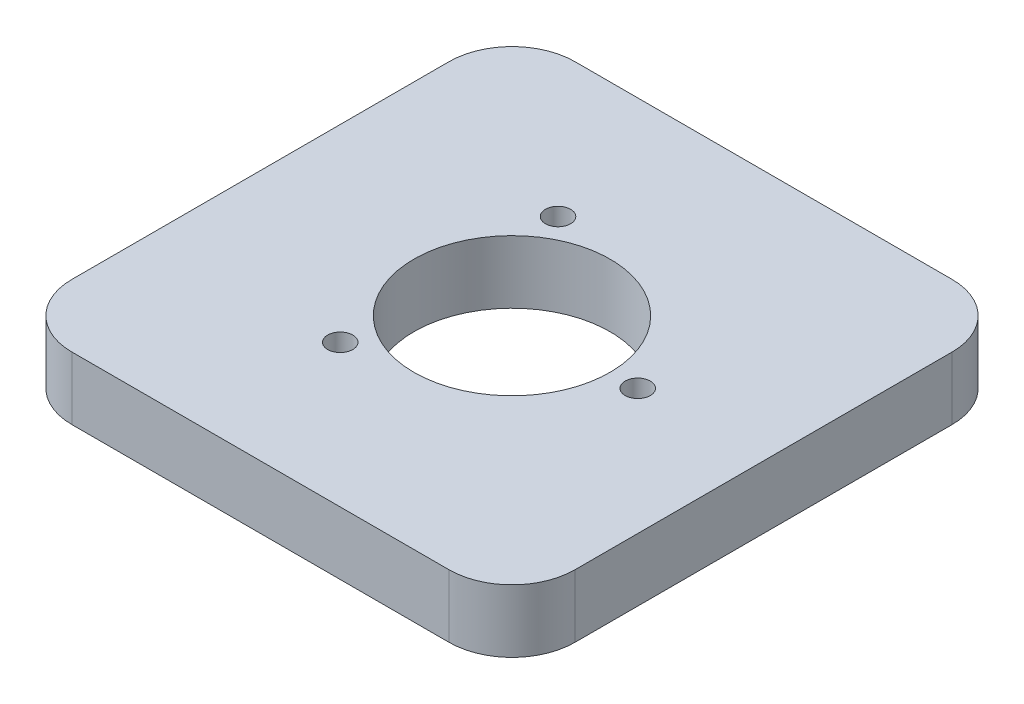
from build123d import *

# Parameters (mm, degrees)
SKETCH1_W           = 50.8
SKETCH1_H           = 50.8
BOSS_EXTRUDE1_DEPTH = 6.35
SKETCH2_R           = 9.906
CUT_EXTRUDE1_DEPTH  = 7.35
SKETCH3_R           = 1.27
CUT_EXTRUDE2_DEPTH  = 7.35
CIRPATTERN1_COUNT   = 3
FILLET1_R           = 6.35


with BuildPart() as part:
    # Sketch1 → Boss-Extrude1 (new body)
    with BuildSketch(Plane(origin=(0, 0, 0), x_dir=(1, 0, 0), z_dir=(0, 1, 0))):
        Rectangle(SKETCH1_W, SKETCH1_H)
    extrude(amount=BOSS_EXTRUDE1_DEPTH)

    # Sketch2 → Cut-Extrude1 (cut, through all)
    with BuildSketch(Plane(origin=(0, 6.35, 0), x_dir=(1, 0, 0), z_dir=(0, 1, 0))):
        Circle(SKETCH2_R)
    extrude(amount=-CUT_EXTRUDE1_DEPTH, mode=Mode.SUBTRACT)

    # Sketch3 → Cut-Extrude2 (cut, through all)
    with BuildSketch(Plane(origin=(0, 6.35, 0), x_dir=(1, 0, 0), z_dir=(0, 1, 0))):
        with Locations((12.7, 0)):
            Circle(SKETCH3_R)
    cut_extrude2 = extrude(amount=-CUT_EXTRUDE2_DEPTH, mode=Mode.SUBTRACT)

    # CirPattern1: Cut-Extrude2 ×3 about axis
    cirpattern1_axis = Axis((0, 0, 0), (0, 1, 0))
    for i in range(1, CIRPATTERN1_COUNT):
        add(cut_extrude2.rotate(cirpattern1_axis, i * 360 / CIRPATTERN1_COUNT), mode=Mode.SUBTRACT)

    # Fillet1
    fillet1_edges = [part.edges().sort_by_distance(p)[0] for p in [
        (25.4, 3.175, 25.4),
        (-25.4, 3.175, 25.4),
        (-25.4, 3.175, -25.4),
        (25.4, 3.175, -25.4),
    ]]
    fillet(fillet1_edges, radius=FILLET1_R)


solid = part.part
